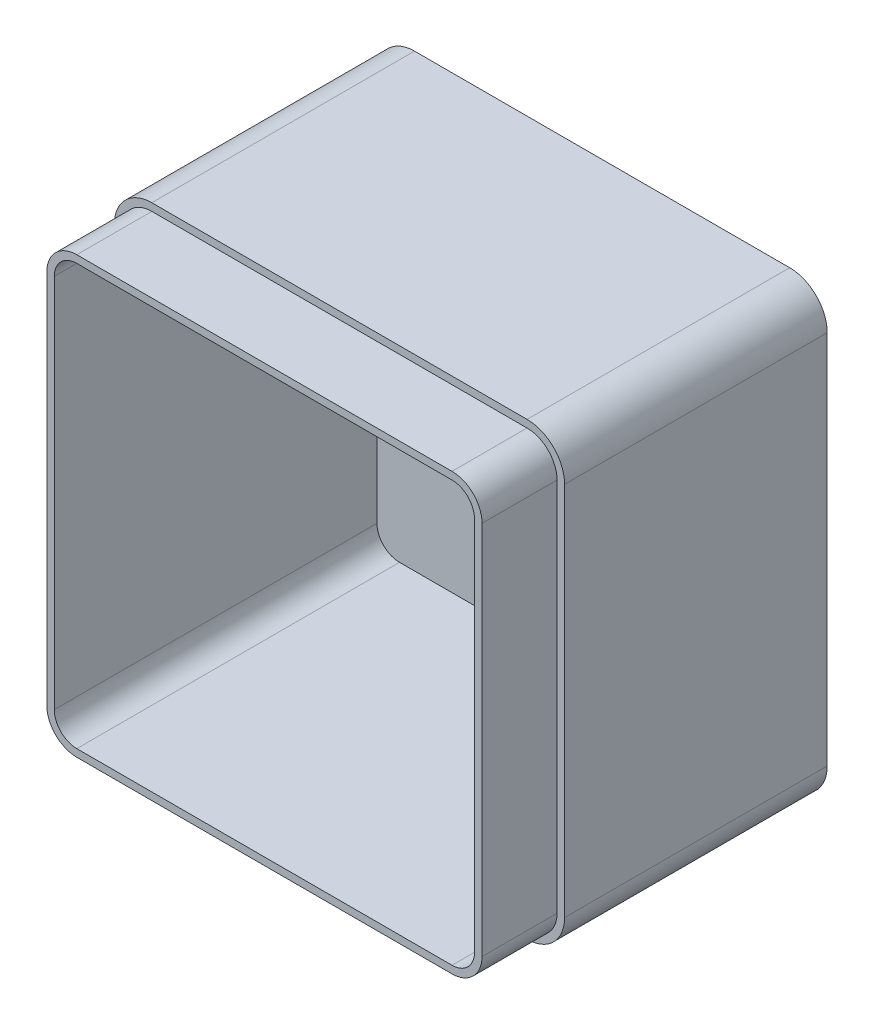
from build123d import *

# Parameters (mm, degrees)
SKETCH1_W           = 120
SKETCH1_H           = 120
BOSS_EXTRUDE1_DEPTH = 90
FILLET1_R           = 10
SHELL3_T            = -4
CUT_EXTRUDE1_DEPTH  = 20


with BuildPart() as part:
    # Sketch1 → Boss-Extrude1 (new body)
    with BuildSketch(Plane.XY):
        with Locations((60, 60)):
            Rectangle(SKETCH1_W, SKETCH1_H)
    extrude(amount=BOSS_EXTRUDE1_DEPTH)

    # Fillet1
    fillet1_edges = [part.edges().sort_by_distance(p)[0] for p in [
        (0, 120, 45),
        (120, 120, 45),
        (120, 0, 45),
        (0, 0, 45),
    ]]
    fillet(fillet1_edges, radius=FILLET1_R)

    # Shell3
    shell3_openings = [part.faces().sort_by_distance(p)[0] for p in [
        (60, 60, 90),
    ]]
    offset(amount=SHELL3_T, openings=shell3_openings, kind=Kind.INTERSECTION)

    # Sketch2 → Cut-Extrude1 (cut)
    with BuildSketch(Plane.XY.offset(90)):
        with BuildLine():
            Line((10, 0), (110, 0))
            ThreePointArc((110, 0), (117.071067812, 2.928932188), (120, 10))
            Line((120, 10), (120, 110))
            ThreePointArc((120, 110), (117.071067812, 117.071067812), (110, 120))
            Line((110, 120), (10, 120))
            ThreePointArc((10, 120), (2.928932188, 117.071067812), (0, 110))
            Line((0, 110), (0, 10))
            ThreePointArc((0, 10), (2.928932188, 2.928932188), (10, 0))
        make_face()
        with BuildLine():
            Line((10, 2), (110, 2))
            ThreePointArc((110, 2), (115.656854249, 4.343145751), (118, 10))
            Line((118, 10), (118, 110))
            ThreePointArc((118, 110), (115.656854249, 115.656854249), (110, 118))
            Line((110, 118), (10, 118))
            ThreePointArc((10, 118), (4.343145751, 115.656854249), (2, 110))
            Line((2, 110), (2, 10))
            ThreePointArc((2, 10), (4.343145751, 4.343145751), (10, 2))
        make_face(mode=Mode.SUBTRACT)
    extrude(amount=-CUT_EXTRUDE1_DEPTH, mode=Mode.SUBTRACT)


solid = part.part
